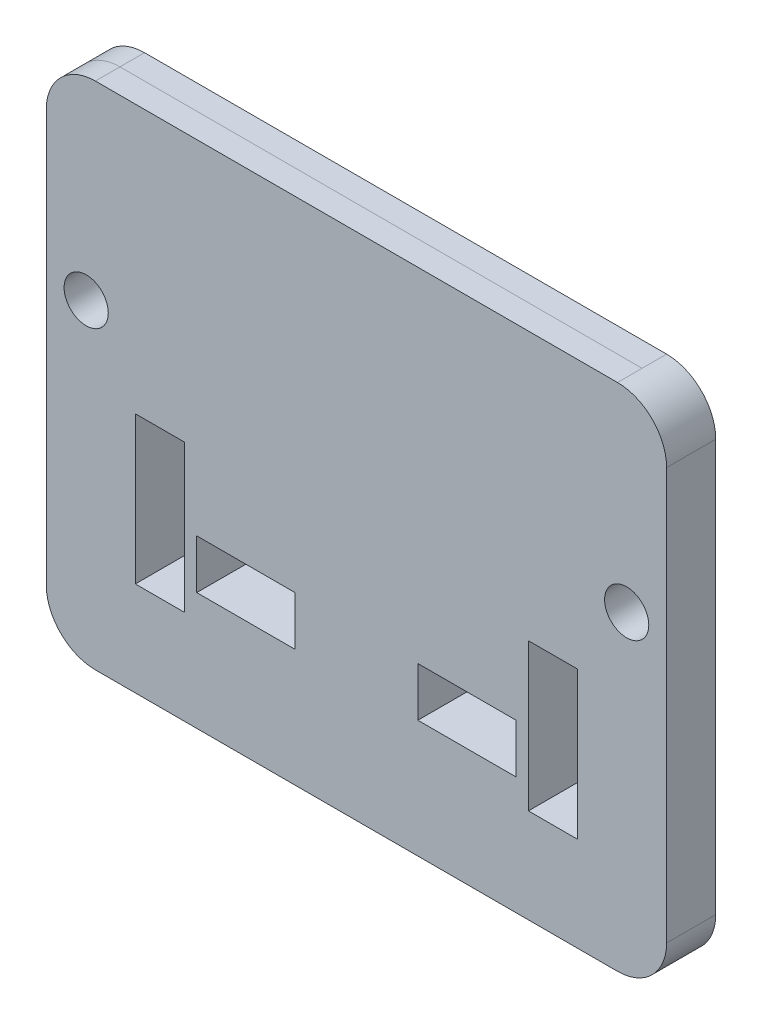
from build123d import *

# Parameters (mm, degrees)
SKETCH1_R                      = 11.422
BOSS_EXTRUDE1_DEPTH            = 25.4
SKETCH2_W                      = 50.8
SKETCH2_H                      = 25.4
FOAM_INSERT_CUT_THROUGHS_DEPTH = 25.4
SKETCH3_W                      = 25.4
SKETCH3_H                      = 76.2
CUT_EXTRUDE1_DEPTH             = 25.4


with BuildPart() as part:
    # Sketch1 → Boss-Extrude1 (new body)
    with BuildSketch(Plane.XY):
        with BuildLine():
            Line((-134.937453137, -131.801904544), (134.937453137, -131.801904544))
            ThreePointArc((134.937453137, -131.801904544), (152.897965379, -124.362416786), (160.337453137, -106.401904544))
            Line((160.337453137, -106.401904544), (160.337453137, 106.401904544))
            ThreePointArc((160.337453137, 106.401904544), (152.897965379, 124.362416786), (134.937453137, 131.801904544))
            Line((134.937453137, 131.801904544), (-134.937453137, 131.801904544))
            ThreePointArc((-134.937453137, 131.801904544), (-152.897965379, 124.362416786), (-160.337453137, 106.401904544))
            Line((-160.337453137, 106.401904544), (-160.337453137, -106.401904544))
            ThreePointArc((-160.337453137, -106.401904544), (-152.897965379, -124.362416786), (-134.937453137, -131.801904544))
        make_face()
        with Locations((-139.7, 31.289898812)):
            Circle(SKETCH1_R, mode=Mode.SUBTRACT)
        with Locations((139.7, 31.289898812)):
            Circle(SKETCH1_R, mode=Mode.SUBTRACT)
    extrude(amount=BOSS_EXTRUDE1_DEPTH)

    # Sketch2 → Foam Insert Cut-Throughs (cut)
    with BuildSketch(Plane(origin=(0, 0, 0), x_dir=(-1, 0, 0), z_dir=(0, 0, -1))):
        with Locations((-57.15, -58.30002437)):
            Rectangle(SKETCH2_W, SKETCH2_H)
        with Locations((57.15, -58.30002437)):
            Rectangle(SKETCH2_W, SKETCH2_H)
    extrude(amount=-FOAM_INSERT_CUT_THROUGHS_DEPTH, mode=Mode.SUBTRACT)

    # Sketch3 (on Front Plane) → Cut-Extrude1 (cut)
    with BuildSketch(Plane.XY):
        with Locations((-101.6, -44.910101188)):
            Rectangle(SKETCH3_W, SKETCH3_H)
        with Locations((101.6, -44.910101188)):
            Rectangle(SKETCH3_W, SKETCH3_H)
    extrude(amount=CUT_EXTRUDE1_DEPTH, mode=Mode.SUBTRACT)


solid = part.part
